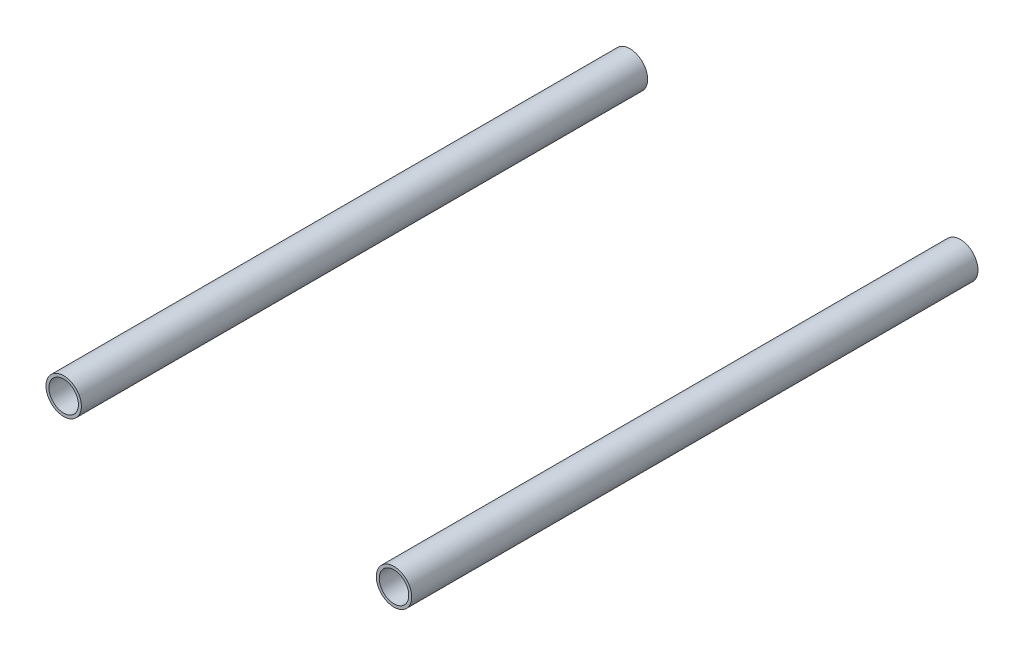
from build123d import *

# Parameters (mm, degrees)
SKETCH1_R             = 9.525
SKETCH1_R_2           = 7.9375
BOSS_EXTRUDE1_DEPTH   = 152.4
BOSS_EXTRUDE1_2_DEPTH = 152.4


with BuildPart() as part:
    # Sketch1 → Boss-Extrude1 (new body, symmetric)
    with BuildSketch(Plane.XY):
        Circle(SKETCH1_R)
        Circle(SKETCH1_R_2, mode=Mode.SUBTRACT)
    extrude(amount=BOSS_EXTRUDE1_DEPTH, both=True)


with BuildPart() as body_2:
    # Sketch1 → Boss-Extrude1 2 (new body, symmetric)
    with BuildSketch(Plane.XY):
        with Locations((177.8, 0)):
            Circle(SKETCH1_R)
        with Locations((177.8, 0)):
            Circle(SKETCH1_R_2, mode=Mode.SUBTRACT)
    extrude(amount=BOSS_EXTRUDE1_2_DEPTH, both=True)


solid = Compound([part.part, body_2.part])
